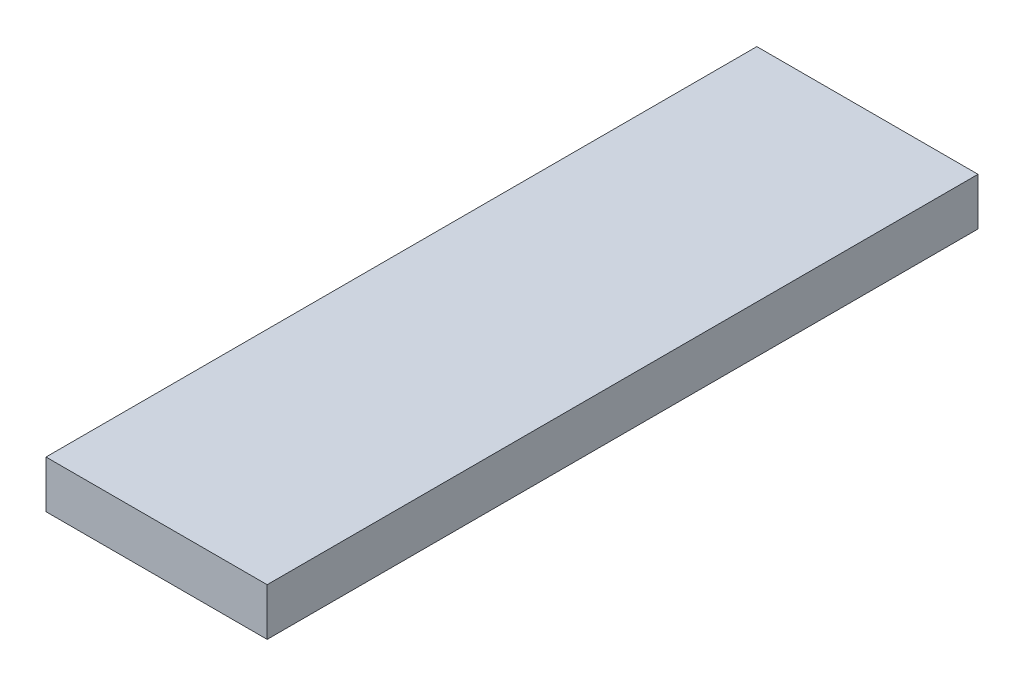
from build123d import *

# Parameters (mm, degrees)
ESQUISSE1_W        = 14
ESQUISSE1_H        = 45
BOSS_EXTRU_1_DEPTH = 3


with BuildPart() as part:
    # Esquisse1 → Boss.-Extru.1 (new body)
    with BuildSketch(Plane(origin=(0, 0, 0), x_dir=(1, 0, 0), z_dir=(0, 1, 0))):
        with Locations((7, 22.5)):
            Rectangle(ESQUISSE1_W, ESQUISSE1_H)
    extrude(amount=BOSS_EXTRU_1_DEPTH)


solid = part.part
